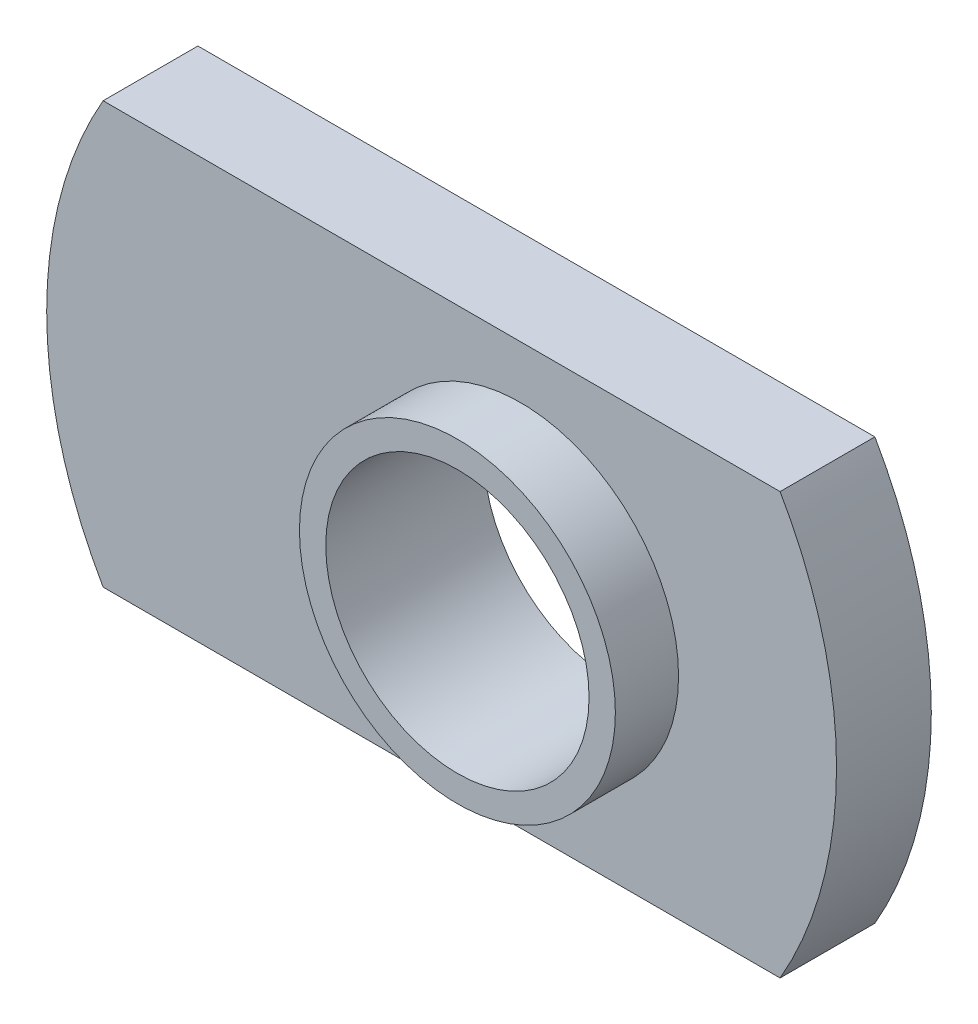
from build123d import *

# Parameters (mm, degrees)
BOSS_EXTRUDE1_DEPTH     = 0.9
SKETCH8_R               = 3
SKETCH8_R_2             = 2.5
BOSS_EXTRUDE2_DEPTH     = 1.2
CUT_EXTRUDE1_DEPTH      = 11.070253224
CUT_EXTRUDE1_DEPTH_BACK = 11.070253224
SKETCH1_R               = 2.5


with BuildPart() as part:
    # Sketch7 → Boss-Extrude1 (new, symmetric)
    with BuildSketch(Plane.XY):
        with BuildLine():
            Line((-7.92820323, 4), (4.92820323, 4))
            ThreePointArc((4.92820323, 4), (6, 0), (4.92820323, -4))
            Line((4.92820323, -4), (-7.92820323, -4))
            ThreePointArc((-7.92820323, -4), (-9, 0), (-7.92820323, 4))
        make_face()
    extrude(amount=BOSS_EXTRUDE1_DEPTH, both=True)

    # Sketch8 → Boss-Extrude2 (add)
    with BuildSketch(Plane.XY.offset(0.9)):
        Circle(SKETCH8_R)
        Circle(SKETCH8_R_2, mode=Mode.SUBTRACT)
    extrude(amount=BOSS_EXTRUDE2_DEPTH)

    # Sketch1 → Cut-Extrude1 (cut, two sides: drawn at the far end of the back side and taken through both)
    with BuildSketch(Plane.XY.offset(-CUT_EXTRUDE1_DEPTH_BACK)):
        Circle(SKETCH1_R)
    extrude(amount=CUT_EXTRUDE1_DEPTH + CUT_EXTRUDE1_DEPTH_BACK, mode=Mode.SUBTRACT)


solid = part.part
